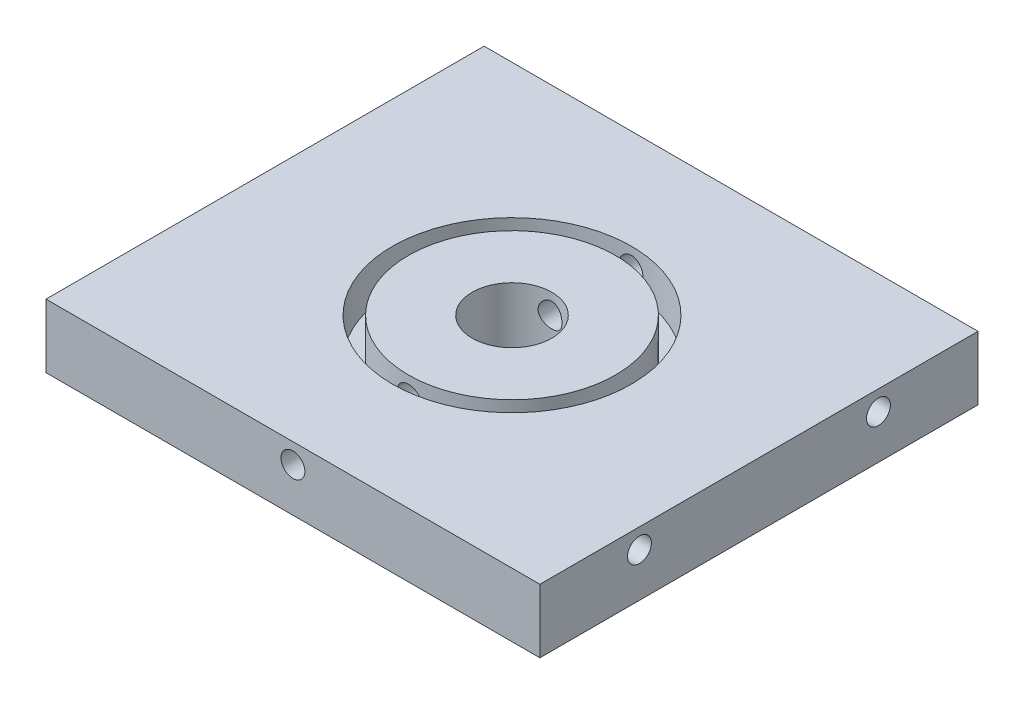
from build123d import *

# Parameters (mm, degrees)
ESQUISSE1_W             = 62
ESQUISSE1_H             = 8
BOSS_EXTRU_1_DEPTH      = 55
ESQUISSE2_R             = 15
ESQUISSE2_R_2           = 13
ENL_V_MAT_EXTRU_1_DEPTH = 5
ESQUISSE3_R             = 1.5
ENL_V_MAT_EXTRU_2_DEPTH = 10
ESQUISSE4_R             = 1.5
ENL_V_MAT_EXTRU_3_DEPTH = 10
ESQUISSE5_R             = 1.5
ENL_V_MAT_EXTRU_4_DEPTH = 56
ESQUISSE6_R             = 5
ENL_V_MAT_EXTRU_5_DEPTH = 9


with BuildPart() as part:
    # Esquisse1 → Boss.-Extru.1 (new body)
    with BuildSketch(Plane.XY):
        with Locations((25.5, -49)):
            Rectangle(ESQUISSE1_W, ESQUISSE1_H)
    extrude(amount=BOSS_EXTRU_1_DEPTH)

    # Esquisse2 → Enlèv. mat.-Extru.1 (cut)
    with BuildSketch(Plane(origin=(0, -45, 0), x_dir=(-1, 0, 0), z_dir=(0, 1, 0))):
        with Locations((-25.5, 27.5)):
            Circle(ESQUISSE2_R)
        with Locations((-25.5, 27.5)):
            Circle(ESQUISSE2_R_2, mode=Mode.SUBTRACT)
    extrude(amount=-ENL_V_MAT_EXTRU_1_DEPTH, mode=Mode.SUBTRACT)

    # Esquisse3 → Enlèv. mat.-Extru.2 (cut)
    with BuildSketch(Plane.ZY.offset(5.5)):
        with Locations((12.5, -47.5)):
            Circle(ESQUISSE3_R)
        with Locations((42.5, -47.5)):
            Circle(ESQUISSE3_R)
    extrude(amount=-ENL_V_MAT_EXTRU_2_DEPTH, mode=Mode.SUBTRACT)

    # Esquisse4 → Enlèv. mat.-Extru.3 (cut)
    with BuildSketch(Plane(origin=(56.5, 0, 0), x_dir=(0, 0, -1), z_dir=(1, 0, 0))):
        with Locations((-42.5, -47.5)):
            Circle(ESQUISSE4_R)
        with Locations((-12.5, -47.5)):
            Circle(ESQUISSE4_R)
    extrude(amount=-ENL_V_MAT_EXTRU_3_DEPTH, mode=Mode.SUBTRACT)

    # Esquisse5 → Enlèv. mat.-Extru.4 (cut, through all)
    with BuildSketch(Plane(origin=(0, 0, 0), x_dir=(-1, 0, 0), z_dir=(0, 0, -1))):
        with Locations((-25.5, -47.5)):
            Circle(ESQUISSE5_R)
    extrude(amount=-ENL_V_MAT_EXTRU_4_DEPTH, mode=Mode.SUBTRACT)

    # Esquisse6 → Enlèv. mat.-Extru.5 (cut, through all)
    with BuildSketch(Plane(origin=(0, -45, 0), x_dir=(1, 0, 0), z_dir=(0, 1, 0))):
        with Locations((25.5, -27.5)):
            Circle(ESQUISSE6_R)
    extrude(amount=-ENL_V_MAT_EXTRU_5_DEPTH, mode=Mode.SUBTRACT)


solid = part.part
